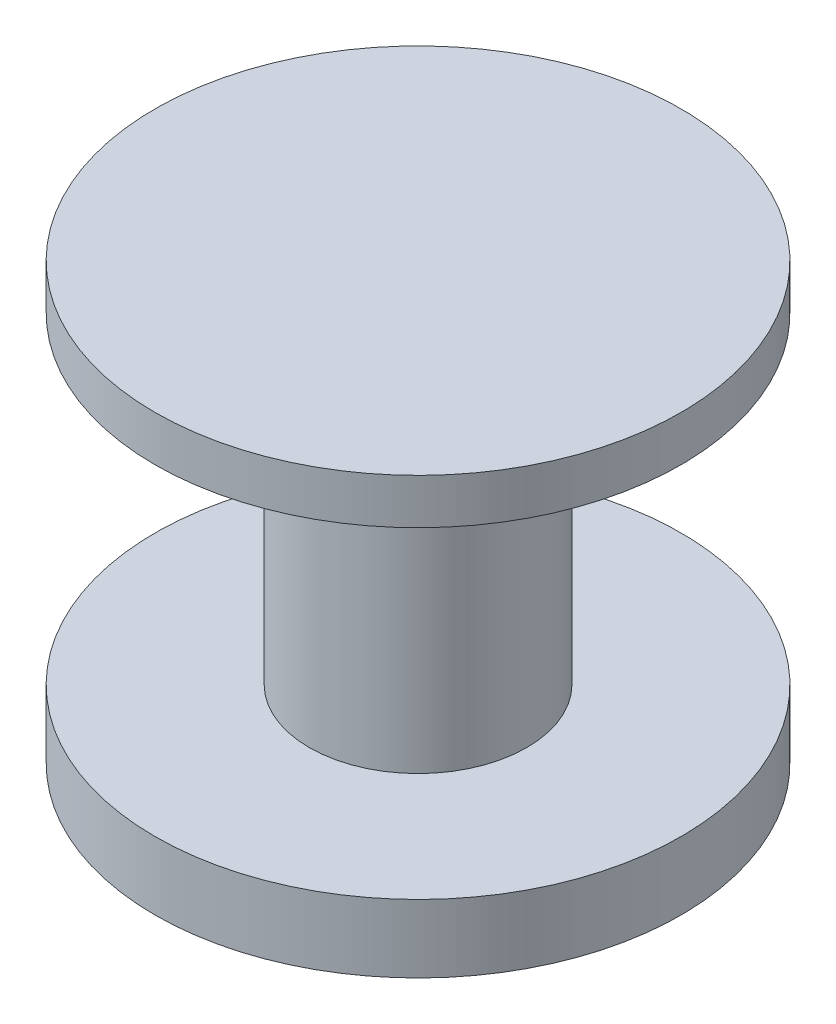
from build123d import *

# Parameters (mm, degrees)
SKETCH1_R           = 2.9
BOSS_EXTRUDE1_DEPTH = 0.75
SKETCH2_R           = 1.2
BOSS_EXTRUDE2_DEPTH = 3.55
SKETCH3_R           = 2.9
BOSS_EXTRUDE3_DEPTH = 0.5


with BuildPart() as part:
    # Sketch1 → Boss-Extrude1 (new body)
    with BuildSketch(Plane(origin=(0, 0, 0), x_dir=(1, 0, 0), z_dir=(0, 1, 0))):
        Circle(SKETCH1_R)
    extrude(amount=BOSS_EXTRUDE1_DEPTH)

    # Sketch2 → Boss-Extrude2 (add)
    with BuildSketch(Plane(origin=(0, 0.75, 0), x_dir=(1, 0, 0), z_dir=(0, 1, 0))):
        Circle(SKETCH2_R)
    extrude(amount=BOSS_EXTRUDE2_DEPTH)

    # Sketch3 → Boss-Extrude3 (add)
    with BuildSketch(Plane(origin=(0, 4.3, 0), x_dir=(1, 0, 0), z_dir=(0, 1, 0))):
        Circle(SKETCH3_R)
    extrude(amount=BOSS_EXTRUDE3_DEPTH)


solid = part.part
